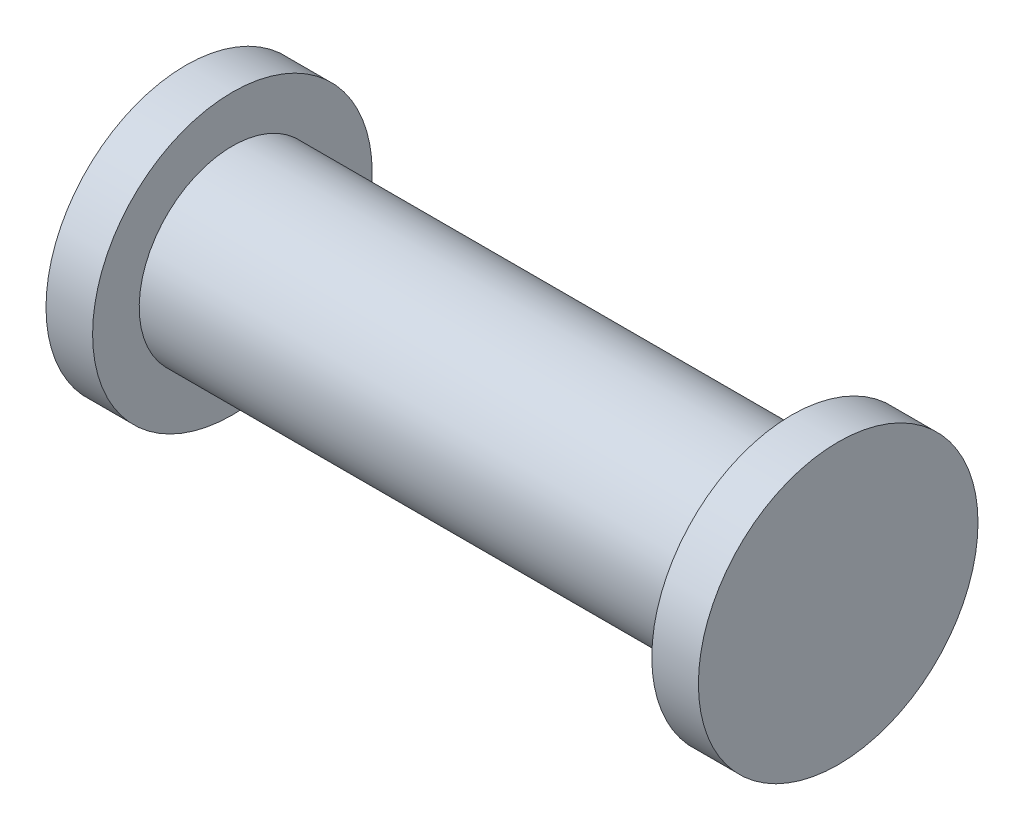
from build123d import *


with BuildPart() as part:
    # Szkic1 → Obrót1 (revolve)
    with BuildSketch(Plane.XY):
        Polygon((0, 0), (6.5, 0), (7, 0), (7, 1.5), (6.5, 1.5), (6.5, 1), (0.5, 1), (0.5, 1.5), (0, 1.5), align=None)
    revolve(axis=Axis((6.5, 0, 0), (1, 0, 0)))


solid = part.part
